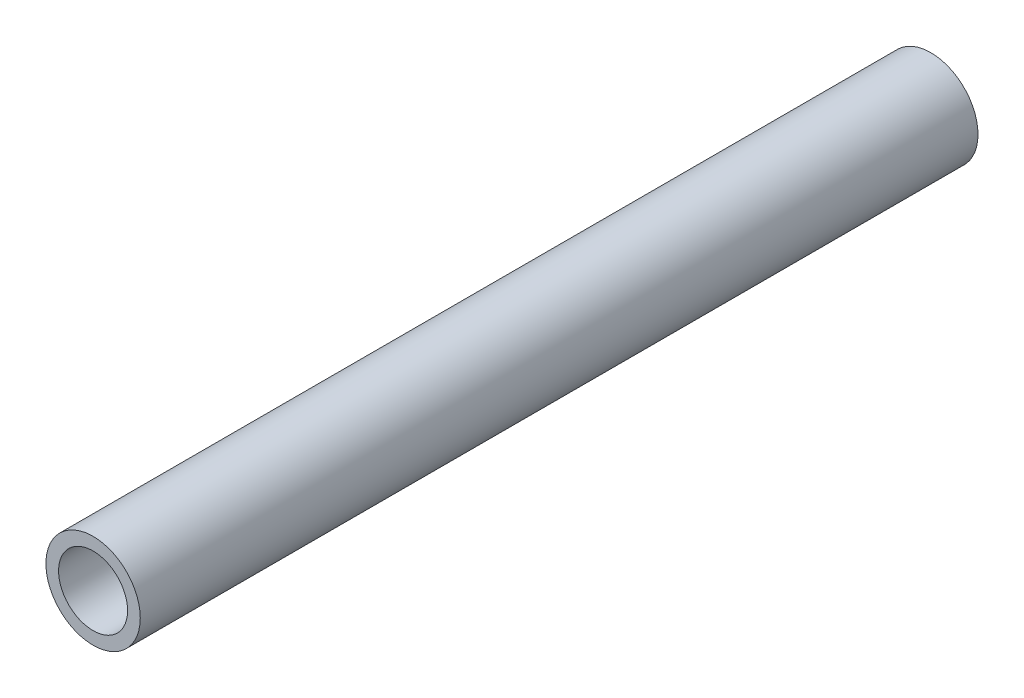
from build123d import *

# Parameters (mm, degrees)
CROQUIS1_R              = 10.7
CROQUIS1_R_2            = 7.825
SALIENTE_EXTRUIR1_DEPTH = 95


with BuildPart() as part:
    # Croquis1 → Saliente-Extruir1 (new body, symmetric)
    with BuildSketch(Plane.XY):
        Circle(CROQUIS1_R)
        Circle(CROQUIS1_R_2, mode=Mode.SUBTRACT)
    extrude(amount=SALIENTE_EXTRUIR1_DEPTH, both=True)


solid = part.part
